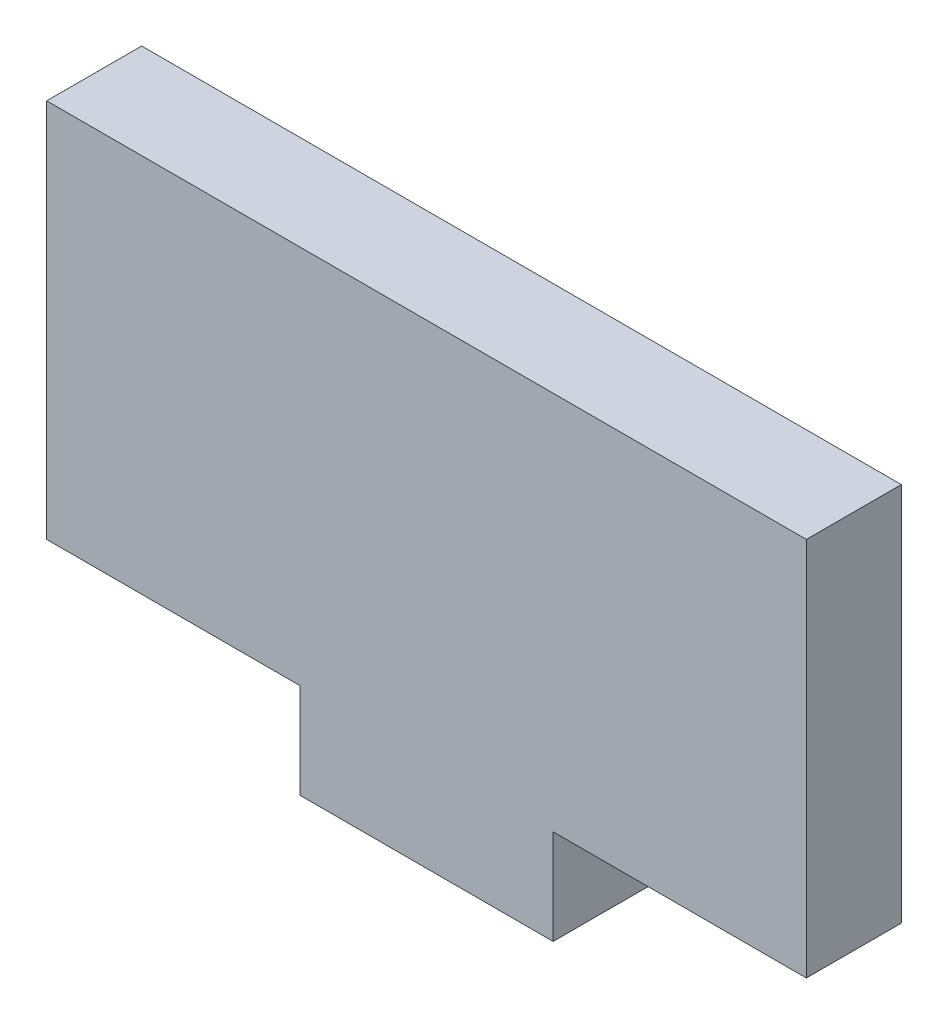
from build123d import *

# Parameters (mm, degrees)
BOSS_EXTRUDE1_DEPTH = 6.35


with BuildPart() as part:
    # Sketch1 → Boss-Extrude1 (new body)
    with BuildSketch(Plane.XY):
        Polygon((33.866666667, 0), (50.8, 0), (50.8, 25.4), (0, 25.4), (0, 0), (16.933333333, 0), (16.933333333, -6.35), (33.866666667, -6.35), align=None)
    extrude(amount=BOSS_EXTRUDE1_DEPTH)


solid = part.part
